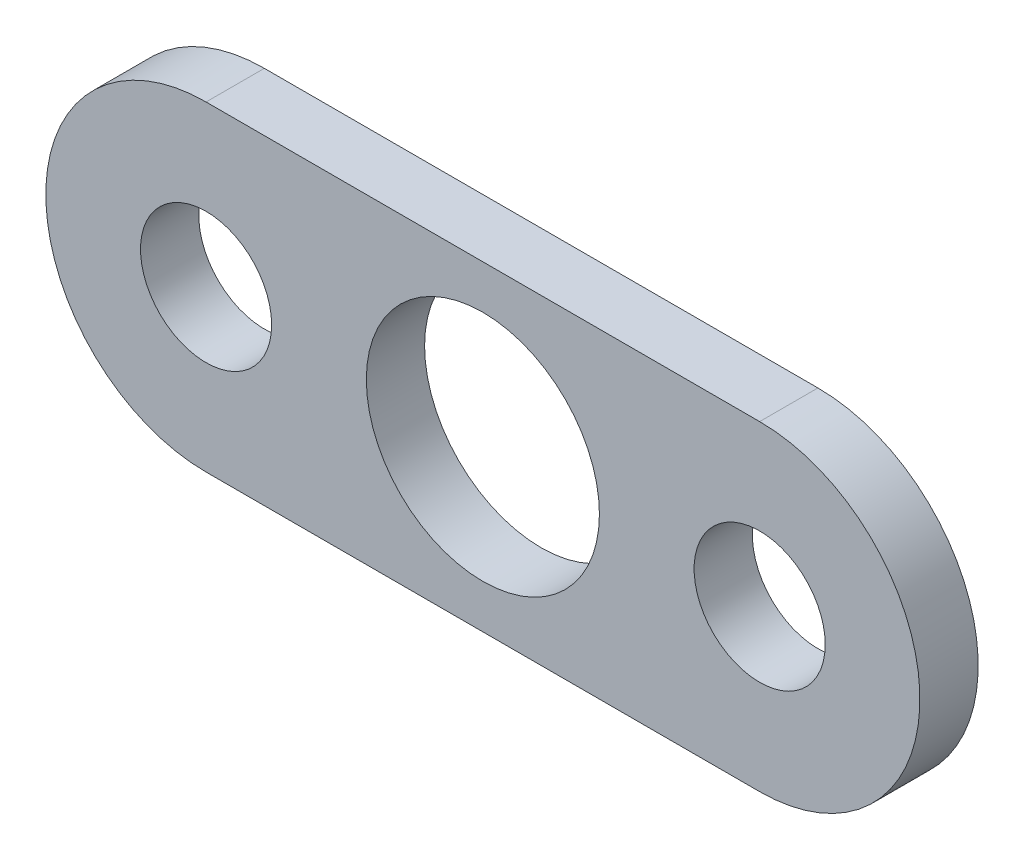
from build123d import *

# Parameters (mm, degrees)
SKETCH1_R            = 4
BOSS_EXTRUDE1_DEPTH  = 2
M4_CLEARANCE_HOLE1_D = 4.5


with BuildPart() as part:
    # Sketch1 → Boss-Extrude1 (new body)
    with BuildSketch(Plane.XY):
        with BuildLine():
            Line((-9.5, 5.5), (9.5, 5.5))
            ThreePointArc((9.5, 5.5), (15, 0), (9.5, -5.5))
            Line((9.5, -5.5), (-9.5, -5.5))
            ThreePointArc((-9.5, -5.5), (-15, 0), (-9.5, 5.5))
        make_face()
        Circle(SKETCH1_R, mode=Mode.SUBTRACT)
    extrude(amount=BOSS_EXTRUDE1_DEPTH)

    # M4 Clearance Hole1 (through all)
    with Locations(Plane.XY.offset(2)):
        with Locations((-9.5, 0), (9.5, 0)):
            Hole(M4_CLEARANCE_HOLE1_D / 2)


solid = part.part
